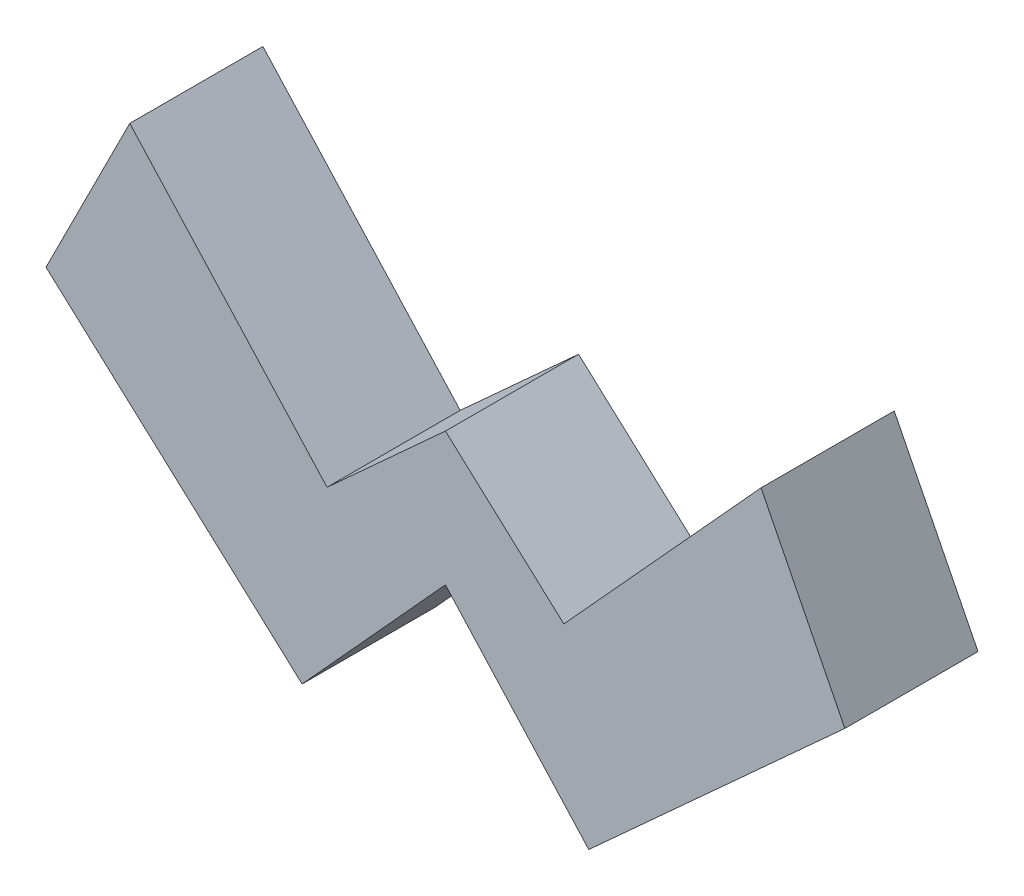
from build123d import *

# Parameters (mm, degrees)
BOSS_EXTRUDE1_DEPTH = 5


with BuildPart() as part:
    # Sketch2 → Boss-Extrude1 (new body)
    with BuildSketch(Plane.XY):
        Polygon((0, 5), (4.44647335, 0.949658378), (11.853974226, 9.081628051), (15, 2.828427125), (5.382645584, -5.918371949), (0, 0), align=None)
        Polygon((-15, 2.828427125), (-5.382645584, -5.918371949), (0, 0), (0, 5), (-4.44647335, 0.949658378), (-11.853974226, 9.081628051), align=None)
    extrude(amount=BOSS_EXTRUDE1_DEPTH)


solid = part.part
